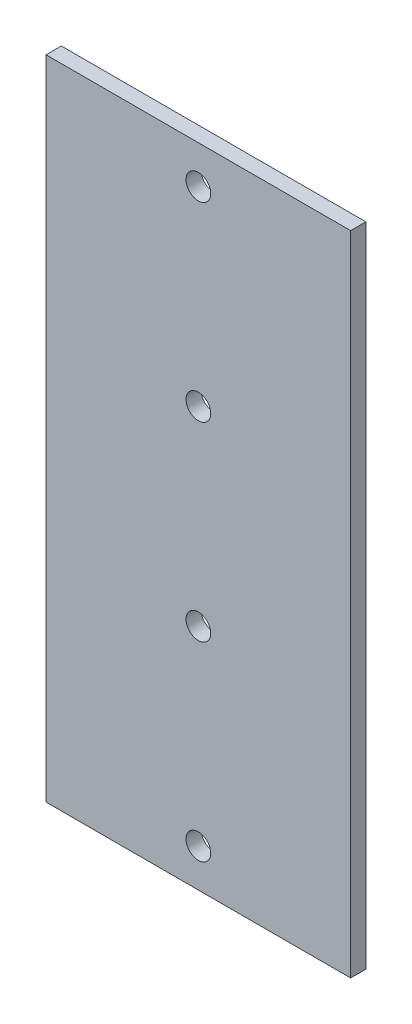
from build123d import *

# Parameters (mm, degrees)
SCHIZZO1_W                   = 40
SCHIZZO1_H                   = 85
ESTRUSIONE_ESTRUSIONE1_DEPTH = 1
SCHIZZO2_R                   = 1.625
TAGLIO_ESTRUSIONE1_DEPTH     = 2
RIPETIZIONE_A_L1_COUNT       = 4
RIPETIZIONE_A_L1_PITCH       = 25


with BuildPart() as part:
    # Schizzo1 → Estrusione-Estrusione1 (new body, symmetric)
    with BuildSketch(Plane.XY):
        Rectangle(SCHIZZO1_W, SCHIZZO1_H)
    extrude(amount=ESTRUSIONE_ESTRUSIONE1_DEPTH, both=True)

    # Schizzo2 → Taglio-Estrusione1 (cut)
    with BuildSketch(Plane(origin=(0, 0, -1), x_dir=(-1, 0, 0), z_dir=(0, 0, -1))):
        with Locations((0, 37.5)):
            Circle(SCHIZZO2_R)
    taglio_estrusione1 = extrude(amount=-TAGLIO_ESTRUSIONE1_DEPTH, mode=Mode.SUBTRACT)

    # Ripetizione a L1: Taglio-Estrusione1 ×4
    with Locations(*[(0, -i * RIPETIZIONE_A_L1_PITCH, 0) for i in range(1, RIPETIZIONE_A_L1_COUNT)]):
        add(taglio_estrusione1, mode=Mode.SUBTRACT)


solid = part.part
